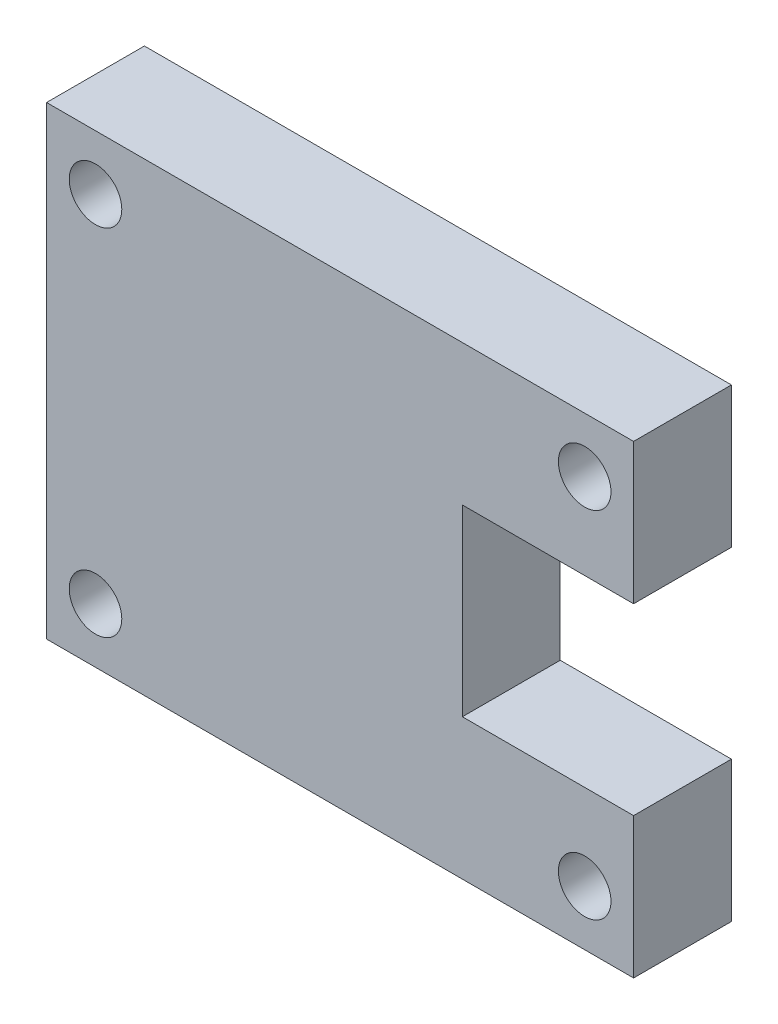
from build123d import *

# Parameters (mm, degrees)
ESQUISSE1_W             = 48
ESQUISSE1_H             = 38
BOSS_EXTRU_1_DEPTH      = 8
ESQUISSE4_W             = 14
ESQUISSE4_H             = 15
ENL_V_MAT_EXTRU_2_DEPTH = 8
D_GAGEMENT_M41_D        = 4.3
D_GAGEMENT_M41_DEPTH    = 10
D_GAGEMENT_M41_TIP      = 1.291850331


with BuildPart() as part:
    # Esquisse1 → Boss.-Extru.1 (new body)
    with BuildSketch(Plane.XY):
        Rectangle(ESQUISSE1_W, ESQUISSE1_H)
    extrude(amount=BOSS_EXTRU_1_DEPTH)

    # Esquisse4 → Enlèv. mat.-Extru.2 (cut)
    with BuildSketch(Plane.XY.offset(8)):
        with Locations((17, 0)):
            Rectangle(ESQUISSE4_W, ESQUISSE4_H)
    extrude(amount=-ENL_V_MAT_EXTRU_2_DEPTH, mode=Mode.SUBTRACT)

    # Dégagement M41
    with Locations(Plane(origin=(-20, 14.5, 8), x_dir=(1, 0, 0), z_dir=(0, 0, 1))):
        with Locations((0, 0), (40, 0), (0, -29), (40, -29)):
            Hole(D_GAGEMENT_M41_D / 2, depth=D_GAGEMENT_M41_DEPTH)
            with Locations((0, 0, -(D_GAGEMENT_M41_DEPTH + D_GAGEMENT_M41_TIP / 2))):  # 118° drill point
                Cone(0, D_GAGEMENT_M41_D / 2, D_GAGEMENT_M41_TIP, mode=Mode.SUBTRACT)


solid = part.part
